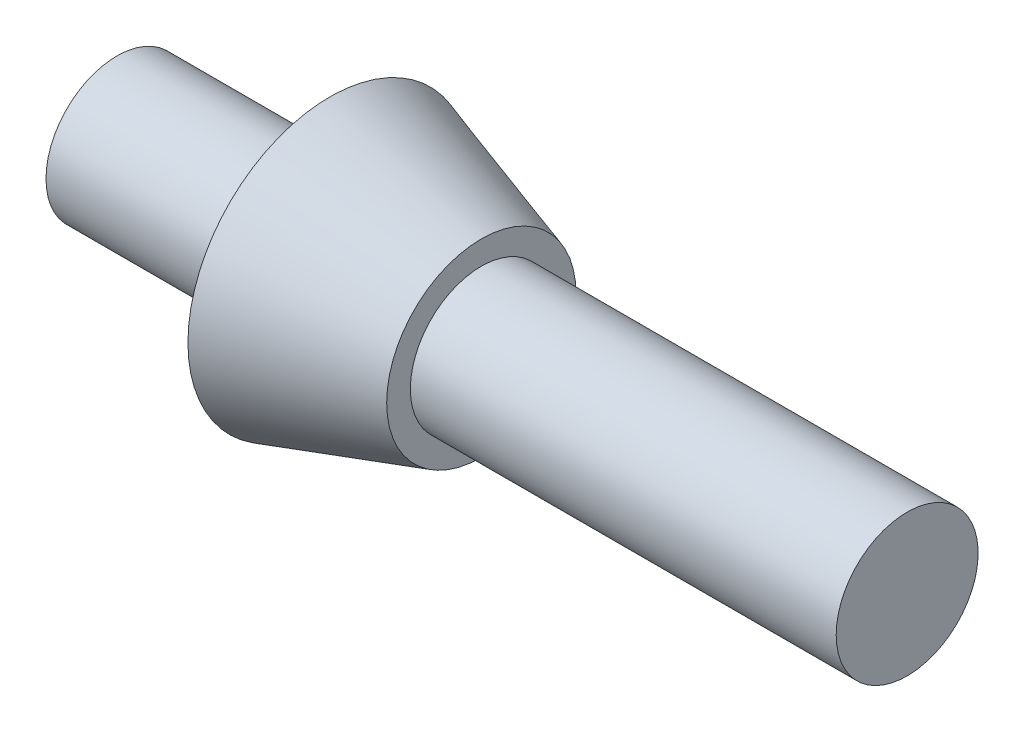
from build123d import *


with BuildPart() as part:
    # 草图1 → 旋转1 (revolve)
    with BuildSketch(Plane.XY):
        Polygon((-9.746319796, 1.5), (-5.246319796, 1.5), (-5.246319796, 3), (-2.046319796, 2), (-2.046319796, 1.5), (6.953680204, 1.5), (6.953680204, 0), (-9.746319796, 0), align=None)
    revolve(axis=Axis((-51.730151438, 0, 0), (1, 0, 0)))


solid = part.part
